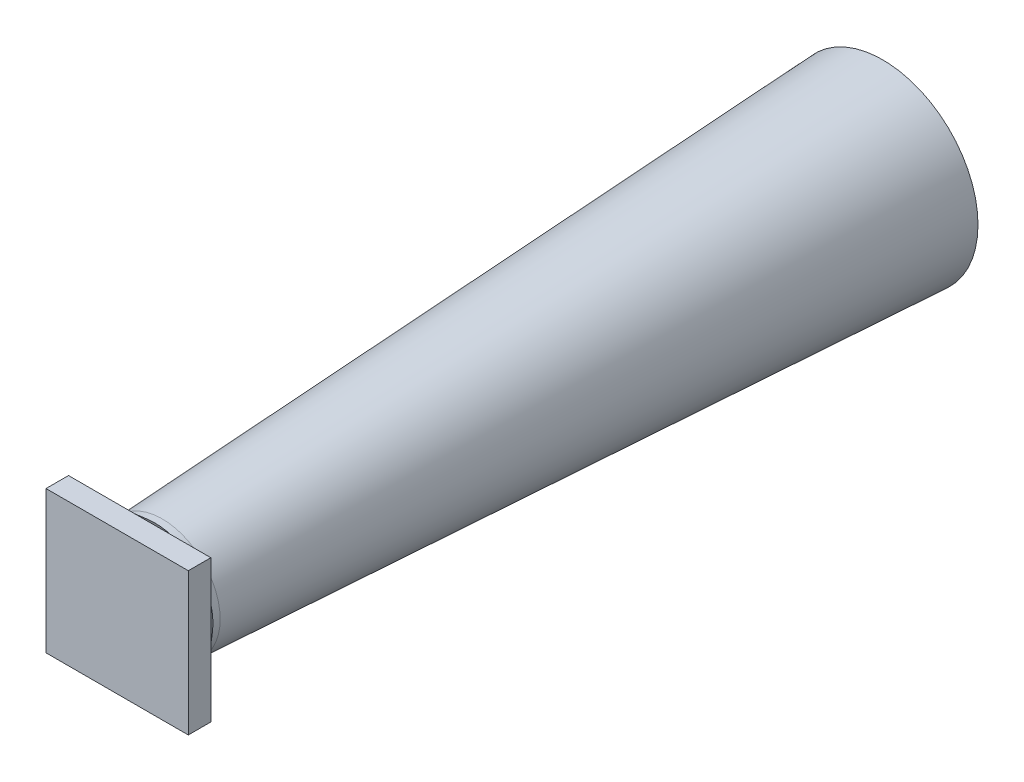
from build123d import *

# Parameters (mm, degrees)
SKETCH1_R           = 1.321708294
SKETCH2_R           = 0.804719078
SKETCH5_R           = 0.804719078
BOSS_EXTRUDE2_DEPTH = 0.1
SKETCH6_R           = 0.804719078
SKETCH7_R           = 0.987442809
SKETCH8_W           = 1.974885617
SKETCH8_H           = 1.974885617
BOSS_EXTRUDE3_DEPTH = 0.3125


with BuildPart() as part:
    # Sketch1 → Loft1 section 0
    with BuildSketch(Plane.XY):
        with Locations((7.853314297, -30.890436458)):
            Circle(SKETCH1_R)
    # Sketch2 → Loft1 section 1
    with BuildSketch(Plane.XY.offset(10)):
        with Locations((7.853314297, -30.890436458)):
            Circle(SKETCH2_R)
    loft()

    # Sketch5 → Boss-Extrude2 (add)
    with BuildSketch(Plane.XY.offset(10)):
        with Locations((7.853314297, -30.890436458)):
            Circle(SKETCH5_R)
    extrude(amount=BOSS_EXTRUDE2_DEPTH)

    # Sketch6 → Loft2 section 0
    with BuildSketch(Plane.XY.offset(10.1)):
        with Locations((7.853314297, -30.890436458)):
            Circle(SKETCH6_R)
    # Sketch7 → Loft2 section 1
    with BuildSketch(Plane.XY.offset(10.3125)):
        with Locations((7.853314297, -30.890436458)):
            Circle(SKETCH7_R)
    loft()

    # Sketch8 → Boss-Extrude3 (add)
    with BuildSketch(Plane.XY.offset(10.3125)):
        with Locations((7.853314298, -30.890436459)):
            Rectangle(SKETCH8_W, SKETCH8_H)
    extrude(amount=BOSS_EXTRUDE3_DEPTH)


solid = part.part
